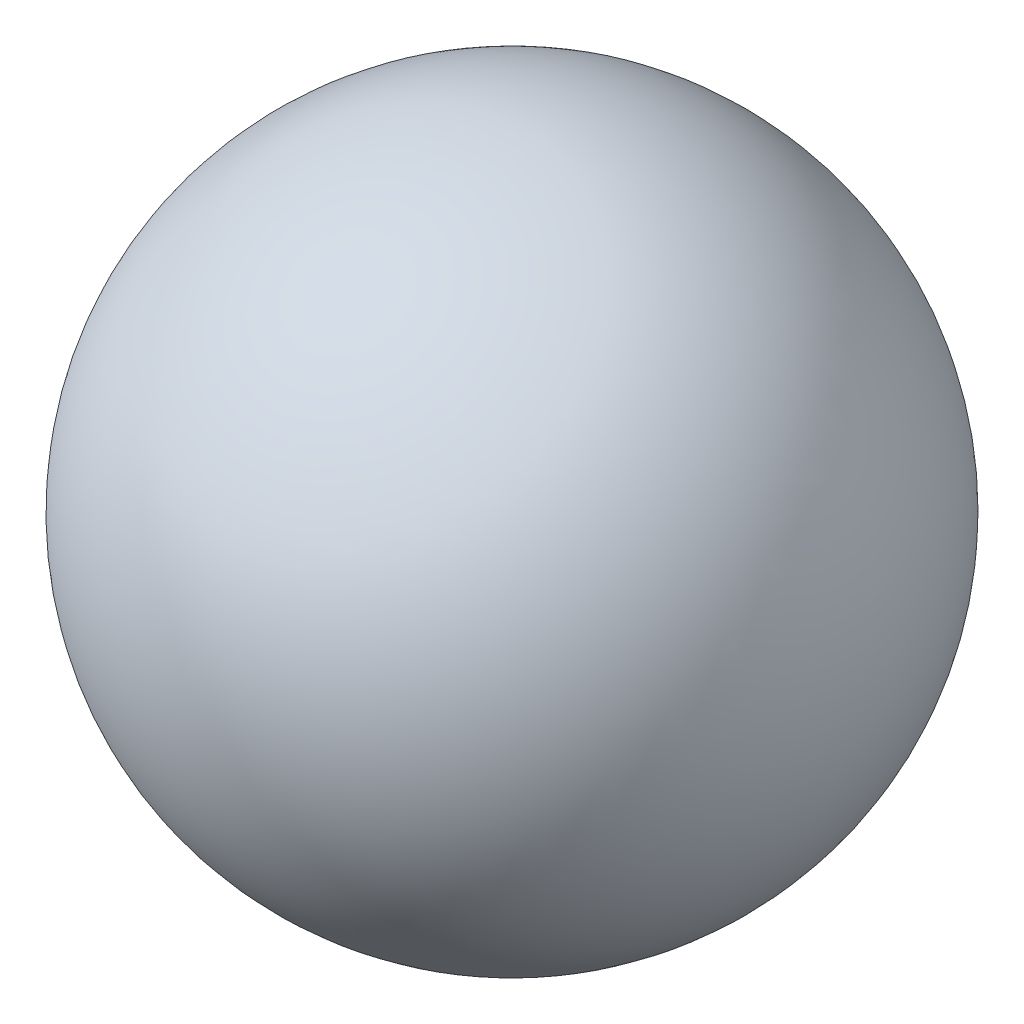
from build123d import *

# Parameters (mm, degrees)
SKETCH2_R          = 2
CUT_EXTRUDE1_DEPTH = 6


with BuildPart() as part:
    # Sketch1 one side → Revolve2 (revolve)
    with BuildSketch(Plane.XY):
        with BuildLine():
            ThreePointArc((0, -5), (3.535533906, -3.535533906), (5, 0))
            ThreePointArc((5, 0), (3.535533906, 3.535533906), (0, 5))
            Line((0, 5), (0, -5))
        make_face()
    revolve(axis=Axis((0, 5, 0), (0, -1, 0)))

    # Sketch2 → Cut-Extrude1 (cut, through all)
    with BuildSketch(Plane(origin=(0, 0, 0), x_dir=(1, 0, 0), z_dir=(0, 1, 0))):
        Circle(SKETCH2_R)
    extrude(amount=-CUT_EXTRUDE1_DEPTH, mode=Mode.SUBTRACT)


solid = part.part
